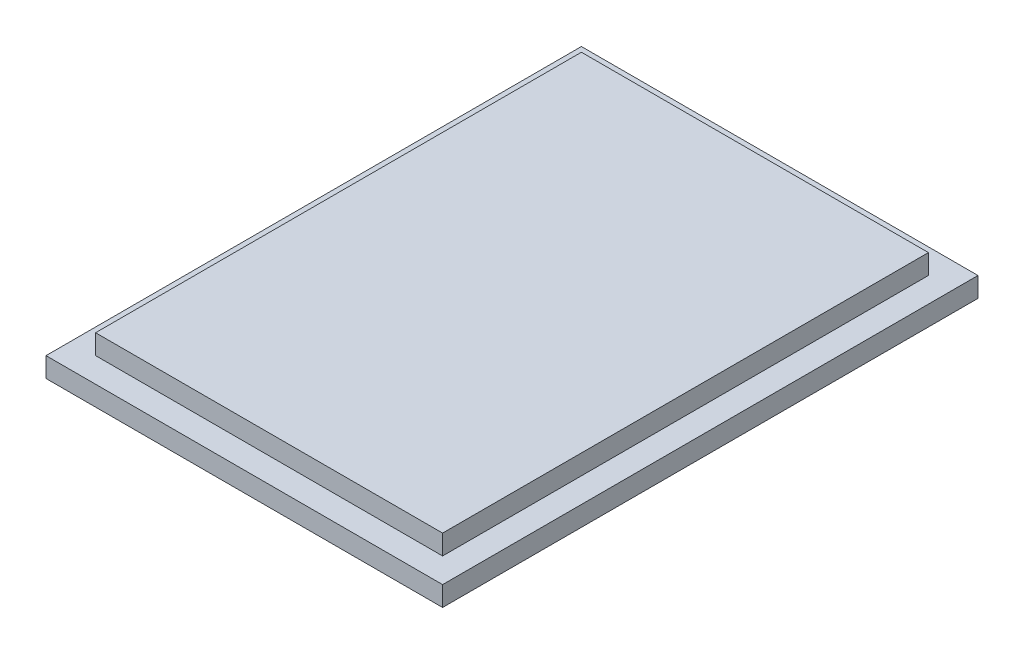
from build123d import *

# Parameters (mm, degrees)
CROQUIS1_W              = 20
CROQUIS1_H              = 27
CROQUIS1_W_2            = 17.5
CROQUIS1_H_2            = 24.5
SALIENTE_EXTRUIR1_DEPTH = 1
CROQUIS1_2_W            = 17.5
CROQUIS1_2_H            = 24.5
SALIENTE_EXTRUIR2_DEPTH = 2


with BuildPart() as part:
    # Croquis1 → Saliente-Extruir1 (new body)
    with BuildSketch(Plane(origin=(0, 0, 0), x_dir=(1, 0, 0), z_dir=(0, 1, 0))):
        with Locations((10, 13.5)):
            Rectangle(CROQUIS1_W, CROQUIS1_H)
        with Locations((10, 13.5)):
            Rectangle(CROQUIS1_W_2, CROQUIS1_H_2, mode=Mode.SUBTRACT)
    extrude(amount=SALIENTE_EXTRUIR1_DEPTH)

    # Croquis1_2 → Saliente-Extruir2 (add)
    with BuildSketch(Plane(origin=(0, 0, 0), x_dir=(1, 0, 0), z_dir=(0, 1, 0))):
        with Locations((10, 13.5)):
            Rectangle(CROQUIS1_2_W, CROQUIS1_2_H)
    extrude(amount=SALIENTE_EXTRUIR2_DEPTH)


solid = part.part
